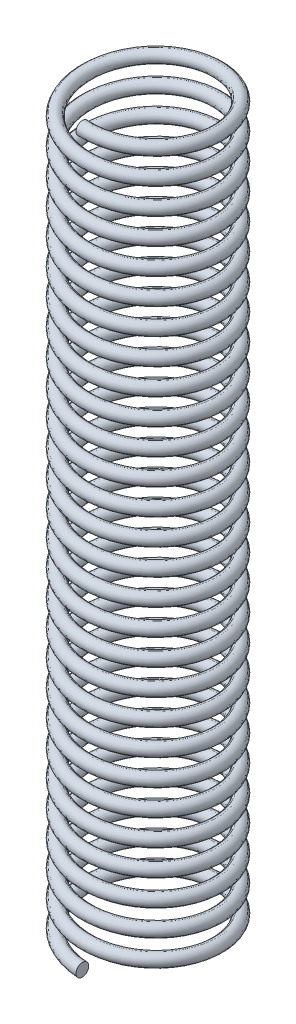
from build123d import *

# Parameters (mm, degrees)
SWEEP1_PITCH  = 3.571428571
SWEEP1_HEIGHT = 100
SWEEP1_RADIUS = 9
SKETCH2_R     = 0.875


with BuildPart() as part:
    # Sweep1: sweep along a helix
    with BuildLine() as sweep1_path:
        Helix(SWEEP1_PITCH, SWEEP1_HEIGHT, SWEEP1_RADIUS, center=(0, 0, 0), direction=(0, 1, 0), lefthand=True)
    # Sketch2 → Sweep1 (sweep)
    with BuildSketch(Plane(origin=(0, 0, 0), x_dir=(0, 0, -1), z_dir=(1, 0, 0))):
        with Locations((-9, 0)):
            Circle(SKETCH2_R)
    sweep(path=sweep1_path.line, is_frenet=True)


solid = part.part
